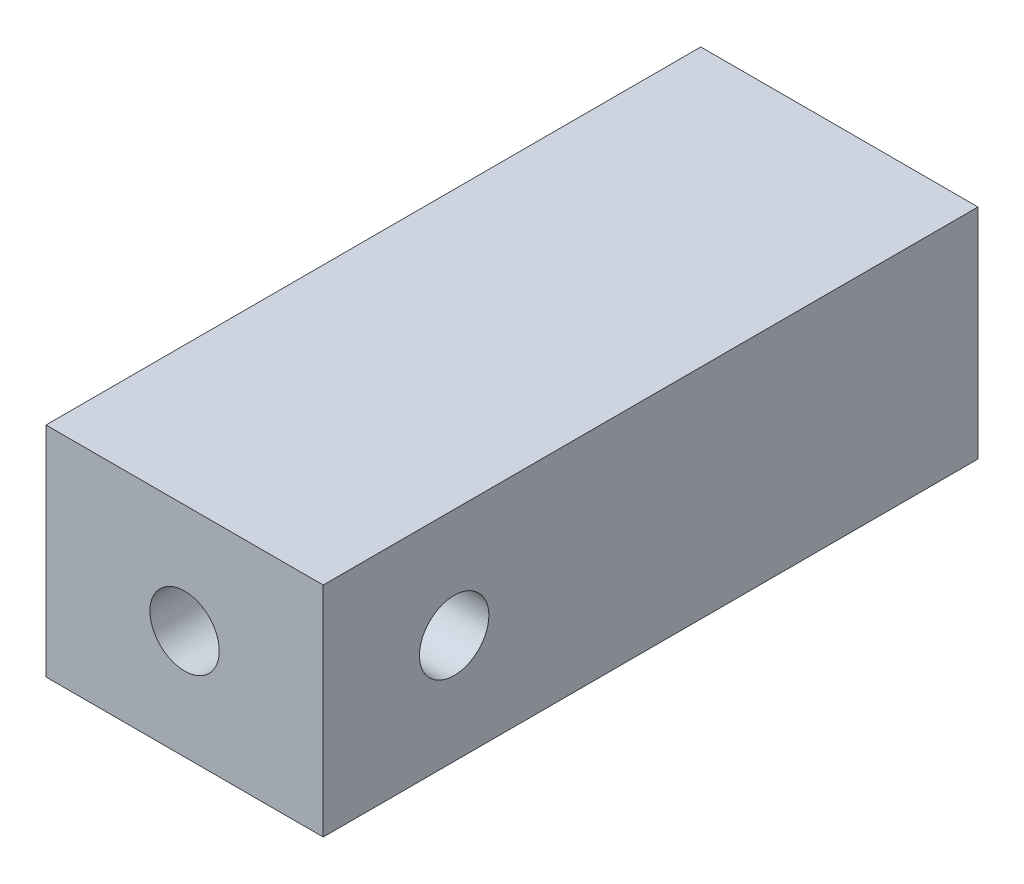
from build123d import *

# Parameters (mm, degrees)
SKETCH1_W           = 12.7
SKETCH1_H           = 10
SKETCH1_R           = 1.5875
BOSS_EXTRUDE1_DEPTH = 30
SKETCH2_R           = 1.59
CUT_EXTRUDE1_DEPTH  = 30


with BuildPart() as part:
    # Sketch1 → Boss-Extrude1 (new body)
    with BuildSketch(Plane.XY):
        with Locations((6.35, -5)):
            Rectangle(SKETCH1_W, SKETCH1_H)
        with Locations((6.35, -5)):
            Circle(SKETCH1_R, mode=Mode.SUBTRACT)
    extrude(amount=BOSS_EXTRUDE1_DEPTH)

    # Sketch2 → Cut-Extrude1 (cut)
    with BuildSketch(Plane(origin=(0, 0, 0), x_dir=(0, 0, -1), z_dir=(1, 0, 0))):
        with Locations((-24, -5)):
            Circle(SKETCH2_R)
    extrude(amount=CUT_EXTRUDE1_DEPTH, mode=Mode.SUBTRACT)


solid = part.part
